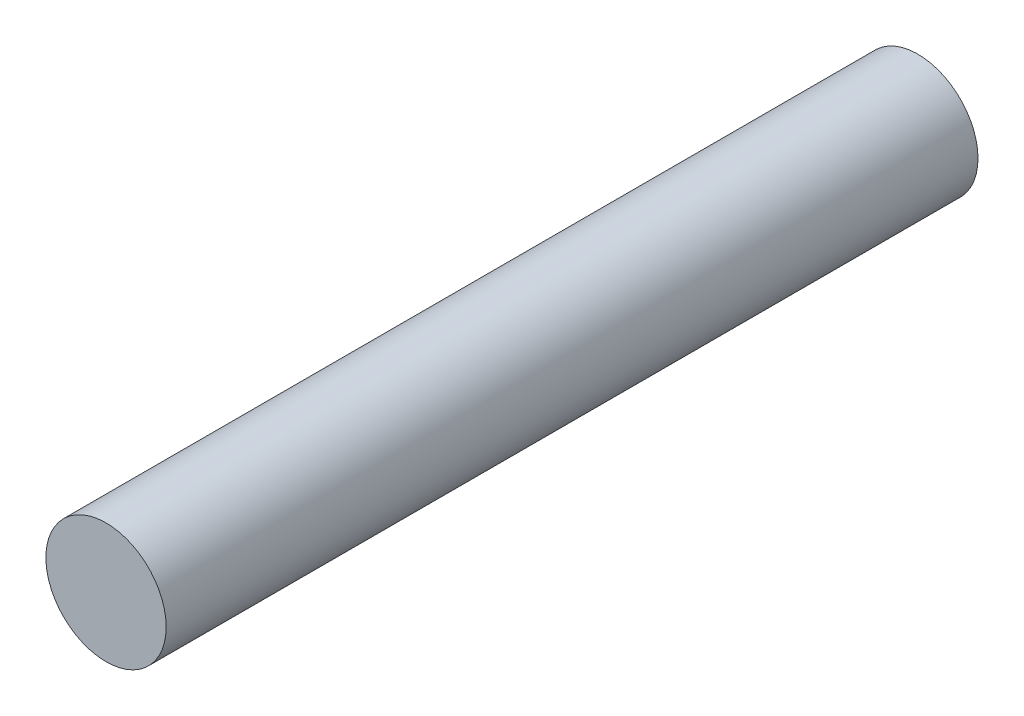
from build123d import *

# Parameters (mm, degrees)
SKETCH1_R           = 4
BOSS_EXTRUDE1_DEPTH = 54


with BuildPart() as part:
    # Sketch1 → Boss-Extrude1 (new body)
    with BuildSketch(Plane.XY):
        with Locations((-52.820279932, 32.884290271)):
            Circle(SKETCH1_R)
    extrude(amount=BOSS_EXTRUDE1_DEPTH)


solid = part.part
